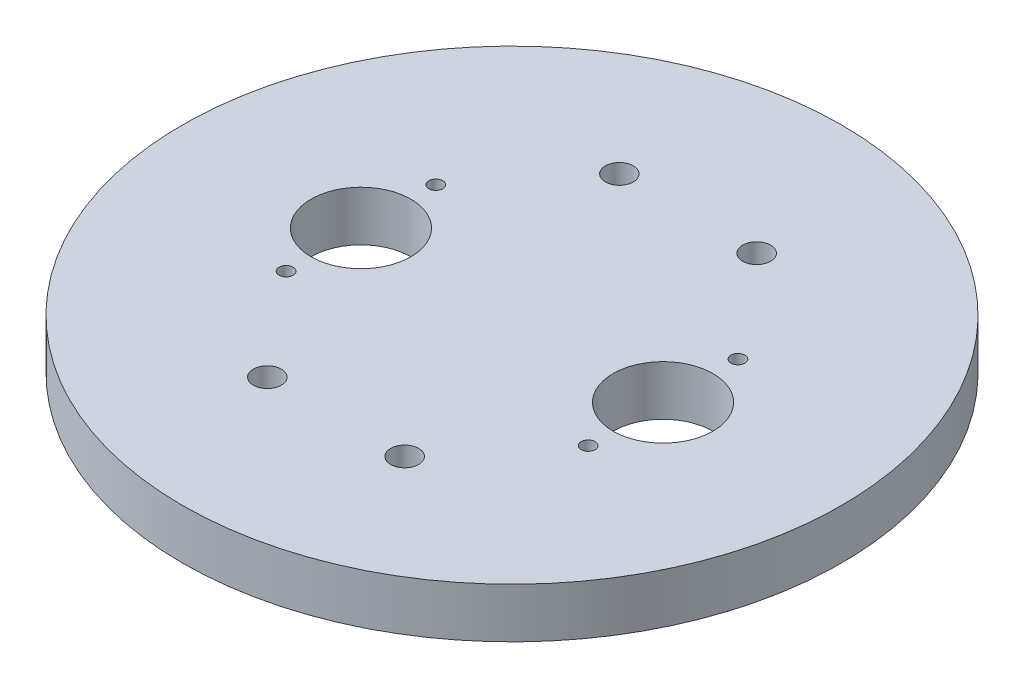
from build123d import *

# Parameters (mm, degrees)
SKETCH1_W                      = 127.635
SKETCH1_H                      = 127.635
MAIN_PLATE_DEPTH               = 12.7
SKETCH9_R                      = 83.82
BOSS_EXTRUDE1_DEPTH            = 12.7
SKETCH10_R                     = 97.039626961
SKETCH10_R_2                   = 83.82
CUT_EXTRUDE1_DEPTH             = 167.64
SKETCH2_R                      = 3.556
U_BOLT_HOLE_DEPTH              = 12.7
U_BOLT_PATTERN_COUNT           = 2
U_BOLT_PATTERN_PITCH           = 34.925
U_BOLT_PATTERN_COUNT_DIR2      = 2
U_BOLT_PATTERN_PITCH_DIR2      = 89.535
SKETCH3_R                      = 1.778
RAPTOR_BOLT_HOLE_DEPTH         = 12.7
RAPTOR_BOLT_PATTERN_COUNT      = 2
RAPTOR_BOLT_PATTERN_PITCH      = 38.1
RAPTOR_BOLT_PATTERN_COUNT_DIR2 = 2
RAPTOR_BOLT_PATTERN_PITCH_DIR2 = 76.835
SKETCH4_R                      = 12.7
CO2_CYLINDER_HOLE_DEPTH        = 12.7
CO2_PATTERN_COUNT              = 2
CO2_PATTERN_PITCH              = 76.835


with BuildPart() as part:
    # Sketch1 → Main Plate (new body)
    with BuildSketch(Plane(origin=(0, 0, 0), x_dir=(1, 0, 0), z_dir=(0, 1, 0))):
        with Locations((63.8175, 63.8175)):
            Rectangle(SKETCH1_W, SKETCH1_H)
    extrude(amount=MAIN_PLATE_DEPTH)

    # Sketch9 → Boss-Extrude1 (add)
    with BuildSketch(Plane(origin=(0, 12.7, 0), x_dir=(1, 0, 0), z_dir=(0, 1, 0))):
        with Locations((63.8175, 63.8175)):
            Circle(SKETCH9_R)
    extrude(amount=-BOSS_EXTRUDE1_DEPTH)

    # Sketch10 → Cut-Extrude1 (cut)
    with BuildSketch(Plane(origin=(0, 12.7, 0), x_dir=(1, 0, 0), z_dir=(0, 1, 0))):
        with Locations((63.8175, 63.8175)):
            Circle(SKETCH10_R)
        with Locations((63.8175, 63.8175)):
            Circle(SKETCH10_R_2, mode=Mode.SUBTRACT)
    extrude(amount=-CUT_EXTRUDE1_DEPTH, mode=Mode.SUBTRACT)

    # Sketch2 → U-Bolt Hole (cut)
    with BuildSketch(Plane(origin=(0, 12.7, 0), x_dir=(1, 0, 0), z_dir=(0, 1, 0))):
        with Locations((46.355, 108.585)):
            Circle(SKETCH2_R)
    u_bolt_hole = extrude(amount=-U_BOLT_HOLE_DEPTH, mode=Mode.SUBTRACT)

    # U-Bolt Pattern: U-Bolt Hole 2 × 2
    with Locations(*[(i * U_BOLT_PATTERN_PITCH, 0, j * U_BOLT_PATTERN_PITCH_DIR2) for i in range(U_BOLT_PATTERN_COUNT) for j in range(U_BOLT_PATTERN_COUNT_DIR2) if (i, j) != (0, 0)]):
        add(u_bolt_hole, mode=Mode.SUBTRACT)

    # Sketch3 → Raptor Bolt Hole (cut)
    with BuildSketch(Plane(origin=(0, 12.7, 0), x_dir=(1, 0, 0), z_dir=(0, 1, 0))):
        with Locations((25.4, 44.7675)):
            Circle(SKETCH3_R)
    raptor_bolt_hole = extrude(amount=-RAPTOR_BOLT_HOLE_DEPTH, mode=Mode.SUBTRACT)

    # Raptor Bolt Pattern: Raptor Bolt Hole 2 × 2
    with Locations(*[(j * RAPTOR_BOLT_PATTERN_PITCH_DIR2, 0, -i * RAPTOR_BOLT_PATTERN_PITCH) for i in range(RAPTOR_BOLT_PATTERN_COUNT) for j in range(RAPTOR_BOLT_PATTERN_COUNT_DIR2) if (i, j) != (0, 0)]):
        add(raptor_bolt_hole, mode=Mode.SUBTRACT)

    # Sketch4 → Co2 Cylinder Hole (cut)
    with BuildSketch(Plane(origin=(0, 12.7, 0), x_dir=(1, 0, 0), z_dir=(0, 1, 0))):
        with Locations((25.4, 63.8175)):
            Circle(SKETCH4_R)
    co2_cylinder_hole = extrude(amount=-CO2_CYLINDER_HOLE_DEPTH, mode=Mode.SUBTRACT)

    # Co2 Pattern: Co2 Cylinder Hole ×2
    with Locations(*[(i * CO2_PATTERN_PITCH, 0, 0) for i in range(1, CO2_PATTERN_COUNT)]):
        add(co2_cylinder_hole, mode=Mode.SUBTRACT)


solid = part.part
